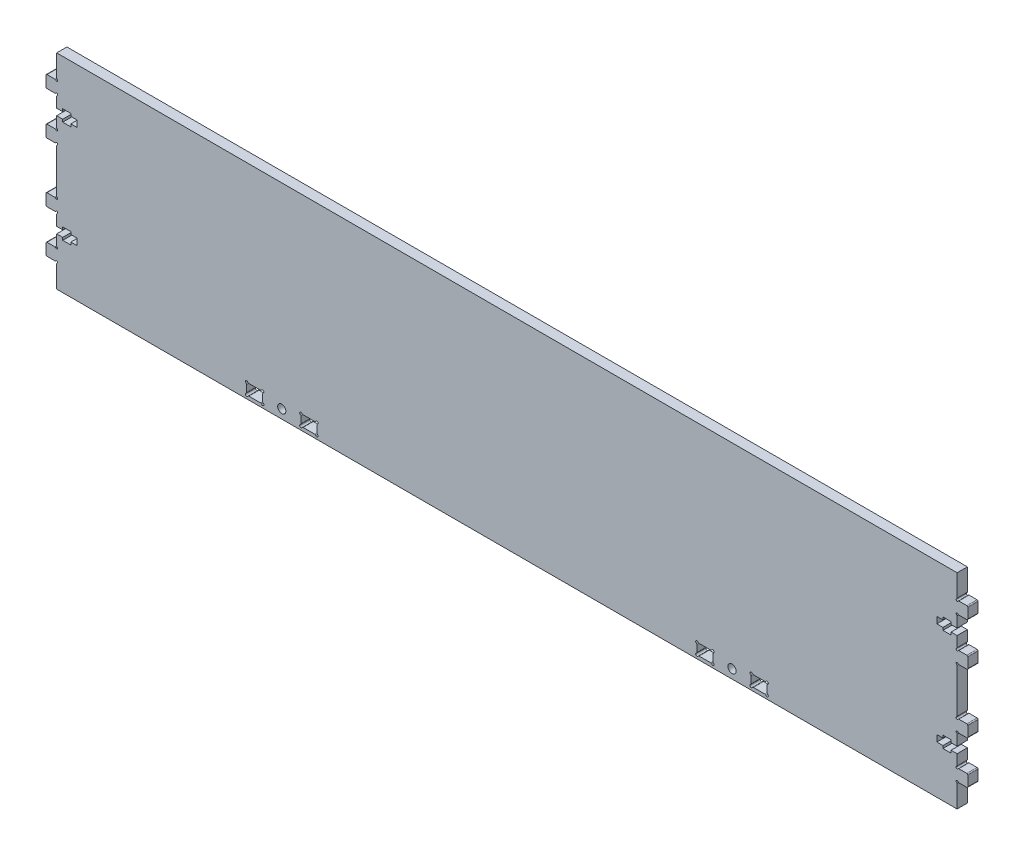
from build123d import *

# Parameters (mm, degrees)
CROQUIS1_R              = 1.6
SALIENTE_EXTRUIR1_DEPTH = 4


with BuildPart() as part:
    # Croquis1 → Saliente-Extruir1 (new body)
    with BuildSketch(Plane.XY):
        with BuildLine():
            Line((-175.998887973, 28.55134284), (-175.998887973, 11.44865157))
            ThreePointArc((-175.998887973, 11.44865157), (-175.94587303, 11.250797196), (-175.801033525, 11.105957783))
            ThreePointArc((-175.801033525, 11.105957783), (-175.719078995, 10.48345621), (-176.341580832, 10.56540874))
            ThreePointArc((-176.341580832, 10.56540874), (-176.486420159, 10.710247461), (-176.684273983, 10.763262086))
            Line((-176.684273983, 10.763262086), (-179.768889347, 10.763262086))
            ThreePointArc((-179.768889347, 10.763262086), (-180.048697583, 10.647361719), (-180.16459795, 10.367553483))
            Line((-180.16459795, 10.367553483), (-180.16459795, 6.410469053))
            ThreePointArc((-180.16459795, 6.410469053), (-180.048697583, 6.130660816), (-179.768889347, 6.01476045))
            Line((-179.768889347, 6.01476045), (-176.68427585, 6.01476045))
            ThreePointArc((-176.68427585, 6.01476045), (-176.48642016, 6.067776152), (-176.341580544, 6.212617529))
            ThreePointArc((-176.341580544, 6.212617529), (-175.719077577, 6.294574818), (-175.801032304, 5.672071513))
            ThreePointArc((-175.801032304, 5.672071513), (-175.945872678, 5.527232006), (-175.998887973, 5.329377021))
            Line((-175.998887973, 5.329377021), (-175.998887973, 1.266269087))
            Line((-175.998887973, 1.266269087), (-173.624658515, 1.266269087))
            Line((-173.624658515, 1.266269087), (-173.624658515, 2.275321276))
            Line((-173.624658515, 2.275321276), (-170.458967533, 2.275321276))
            Line((-170.458967533, 2.275321276), (-170.458967533, 1.266274677))
            Line((-170.458967533, 1.266274677), (-168.084715916, 1.266274677))
            Line((-168.084715916, 1.266274677), (-168.084715916, -1.266274677))
            Line((-168.084715916, -1.266274677), (-170.458967533, -1.266274677))
            Line((-170.458967533, -1.266274677), (-170.458967533, -2.275327657))
            Line((-170.458967533, -2.275327657), (-173.624658515, -2.275327657))
            Line((-173.624658515, -2.275327657), (-173.624658515, -1.266274677))
            Line((-173.624658515, -1.266274677), (-175.998887973, -1.266274677))
            Line((-175.998887973, -1.266274677), (-175.998887973, -5.329405863))
            ThreePointArc((-175.998887973, -5.329405863), (-175.945873032, -5.527260234), (-175.801033533, -5.672099645))
            ThreePointArc((-175.801033533, -5.672099645), (-175.719079017, -6.294601221), (-176.341580852, -6.212648677))
            ThreePointArc((-176.341580852, -6.212648677), (-176.48642018, -6.067809949), (-176.684274007, -6.014795323))
            Line((-176.684274007, -6.014795323), (-179.768889347, -6.014795323))
            ThreePointArc((-179.768889347, -6.014795323), (-180.048697583, -6.130695689), (-180.16459795, -6.410503926))
            Line((-180.16459795, -6.410503926), (-180.16459795, -10.367588371))
            ThreePointArc((-180.16459795, -10.367588371), (-180.048697583, -10.647396608), (-179.768889347, -10.763296974))
            Line((-179.768889347, -10.763296974), (-176.68427585, -10.763296974))
            ThreePointArc((-176.68427585, -10.763296974), (-176.486420241, -10.710281319), (-176.341580638, -10.565440059))
            ThreePointArc((-176.341580638, -10.565440059), (-175.719077737, -10.483482962), (-175.801032398, -11.105986184))
            ThreePointArc((-175.801032398, -11.105986184), (-175.945872705, -11.250825683), (-175.998887973, -11.448680621))
            Line((-175.998887973, -11.448680621), (-175.998887973, -20.000002795))
            Line((-175.998887973, -20.000002795), (176.001112027, -20.000002795))
            Line((176.001112027, -20.000002795), (176.001112027, -11.448677826))
            ThreePointArc((176.001112027, -11.448677826), (175.94809676, -11.250822888), (175.803256453, -11.105983388))
            ThreePointArc((175.803256453, -11.105983388), (175.721301792, -10.483480167), (176.343804693, -10.565437263))
            ThreePointArc((176.343804693, -10.565437263), (176.488644296, -10.710278524), (176.686499905, -10.763294179))
            Line((176.686499905, -10.763294179), (179.771113402, -10.763294179))
            ThreePointArc((179.771113402, -10.763294179), (180.050921638, -10.647393813), (180.166822004, -10.367585576))
            Line((180.166822004, -10.367585576), (180.166822004, -6.41050113))
            ThreePointArc((180.166822004, -6.41050113), (180.050921638, -6.130692894), (179.771113402, -6.014792528))
            Line((179.771113402, -6.014792528), (176.686498062, -6.014792528))
            ThreePointArc((176.686498062, -6.014792528), (176.488644235, -6.067807154), (176.343804907, -6.212645881))
            ThreePointArc((176.343804907, -6.212645881), (175.721303071, -6.294598426), (175.803257588, -5.67209685))
            ThreePointArc((175.803257588, -5.67209685), (175.948097087, -5.527257438), (176.001112027, -5.329403068))
            Line((176.001112027, -5.329403068), (176.001112027, -1.266271882))
            Line((176.001112027, -1.266271882), (173.62688257, -1.266271882))
            Line((173.62688257, -1.266271882), (173.62688257, -2.275324862))
            Line((173.62688257, -2.275324862), (170.461191588, -2.275324862))
            Line((170.461191588, -2.275324862), (170.461191588, -1.266271882))
            Line((170.461191588, -1.266271882), (168.086939971, -1.266271882))
            Line((168.086939971, -1.266271882), (168.086939971, 1.266271882))
            Line((168.086939971, 1.266271882), (170.461191588, 1.266271882))
            Line((170.461191588, 1.266271882), (170.461191588, 2.275324071))
            Line((170.461191588, 2.275324071), (173.62688257, 2.275324071))
            Line((173.62688257, 2.275324071), (173.62688257, 1.266271882))
            Line((173.62688257, 1.266271882), (176.001112027, 1.266271882))
            Line((176.001112027, 1.266271882), (176.001112027, 5.329379817))
            ThreePointArc((176.001112027, 5.329379817), (175.948096732, 5.527234802), (175.803256359, 5.672074308))
            ThreePointArc((175.803256359, 5.672074308), (175.721301631, 6.294577613), (176.343804599, 6.212620324))
            ThreePointArc((176.343804599, 6.212620324), (176.488644215, 6.067778947), (176.686499905, 6.014763245))
            Line((176.686499905, 6.014763245), (179.771113402, 6.014763245))
            ThreePointArc((179.771113402, 6.014763245), (180.050921638, 6.130663611), (180.166822004, 6.410471848))
            Line((180.166822004, 6.410471848), (180.166822004, 10.367556278))
            ThreePointArc((180.166822004, 10.367556278), (180.050921638, 10.647364515), (179.771113402, 10.763264881))
            Line((179.771113402, 10.763264881), (176.686498037, 10.763264881))
            ThreePointArc((176.686498037, 10.763264881), (176.488644214, 10.710250256), (176.343804886, 10.565411535))
            ThreePointArc((176.343804886, 10.565411535), (175.721303049, 10.483459005), (175.80325758, 11.105960579))
            ThreePointArc((175.80325758, 11.105960579), (175.948097085, 11.250799991), (176.001112027, 11.448654365))
            Line((176.001112027, 11.448654365), (176.001112027, 28.551340044))
            ThreePointArc((176.001112027, 28.551340044), (175.948097085, 28.749194419), (175.80325758, 28.894033831))
            ThreePointArc((175.80325758, 28.894033831), (175.721303049, 29.516535405), (176.343804886, 29.434582875))
            ThreePointArc((176.343804886, 29.434582875), (176.488644214, 29.289744153), (176.686498037, 29.236729529))
            Line((176.686498037, 29.236729529), (179.771113402, 29.236729529))
            ThreePointArc((179.771113402, 29.236729529), (180.050921638, 29.352629895), (180.166822004, 29.632438131))
            Line((180.166822004, 29.632438131), (180.166822004, 33.589522562))
            ThreePointArc((180.166822004, 33.589522562), (180.050921638, 33.869330798), (179.771113402, 33.985231164))
            Line((179.771113402, 33.985231164), (176.686499905, 33.985231164))
            ThreePointArc((176.686499905, 33.985231164), (176.488644215, 33.932215462), (176.343804599, 33.787374085))
            ThreePointArc((176.343804599, 33.787374085), (175.721301631, 33.705416797), (175.803256359, 34.327920101))
            ThreePointArc((175.803256359, 34.327920101), (175.948096732, 34.472759608), (176.001112027, 34.670614593))
            Line((176.001112027, 34.670614593), (176.001112027, 38.733722528))
            Line((176.001112027, 38.733722528), (173.62688257, 38.733722528))
            Line((173.62688257, 38.733722528), (173.62688257, 37.724670339))
            Line((173.62688257, 37.724670339), (170.461191588, 37.724670339))
            Line((170.461191588, 37.724670339), (170.461191588, 38.733722528))
            Line((170.461191588, 38.733722528), (168.086939971, 38.733722528))
            Line((168.086939971, 38.733722528), (168.086939971, 41.266266291))
            Line((168.086939971, 41.266266291), (170.461191588, 41.266266291))
            Line((170.461191588, 41.266266291), (170.461191588, 42.275319272))
            Line((170.461191588, 42.275319272), (173.62688257, 42.275319272))
            Line((173.62688257, 42.275319272), (173.62688257, 41.266266291))
            Line((173.62688257, 41.266266291), (176.001112027, 41.266266291))
            Line((176.001112027, 41.266266291), (176.001112027, 45.329397478))
            ThreePointArc((176.001112027, 45.329397478), (175.948097087, 45.527251848), (175.803257588, 45.67209126))
            ThreePointArc((175.803257588, 45.67209126), (175.721303071, 46.294592835), (176.343804907, 46.212640291))
            ThreePointArc((176.343804907, 46.212640291), (176.488644235, 46.067801564), (176.686498062, 46.014786937))
            Line((176.686498062, 46.014786937), (179.771113402, 46.014786937))
            ThreePointArc((179.771113402, 46.014786937), (180.050921638, 46.130687303), (180.166822004, 46.41049554))
            Line((180.166822004, 46.41049554), (180.166822004, 50.367579986))
            ThreePointArc((180.166822004, 50.367579986), (180.050921638, 50.647388222), (179.771113402, 50.763288589))
            Line((179.771113402, 50.763288589), (176.686499905, 50.763288589))
            ThreePointArc((176.686499905, 50.763288589), (176.488644296, 50.710272934), (176.343804693, 50.565431673))
            ThreePointArc((176.343804693, 50.565431673), (175.721301792, 50.483474576), (175.803256453, 51.105977798))
            ThreePointArc((175.803256453, 51.105977798), (175.94809676, 51.250817297), (176.001112027, 51.448672235))
            Line((176.001112027, 51.448672235), (176.001112027, 59.999997205))
            Line((176.001112027, 59.999997205), (-175.998887973, 59.999997205))
            Line((-175.998887973, 59.999997205), (-175.998887973, 51.44867503))
            ThreePointArc((-175.998887973, 51.44867503), (-175.945872705, 51.250820093), (-175.801032398, 51.105980593))
            ThreePointArc((-175.801032398, 51.105980593), (-175.719077737, 50.483477372), (-176.341580638, 50.565434468))
            ThreePointArc((-176.341580638, 50.565434468), (-176.486420241, 50.710275729), (-176.68427585, 50.763291384))
            Line((-176.68427585, 50.763291384), (-179.768889347, 50.763291384))
            ThreePointArc((-179.768889347, 50.763291384), (-180.048697583, 50.647391017), (-180.16459795, 50.367582781))
            Line((-180.16459795, 50.367582781), (-180.16459795, 46.410498335))
            ThreePointArc((-180.16459795, 46.410498335), (-180.048697583, 46.130690099), (-179.768889347, 46.014789732))
            Line((-179.768889347, 46.014789732), (-176.684274007, 46.014789732))
            ThreePointArc((-176.684274007, 46.014789732), (-176.48642018, 46.067804359), (-176.341580852, 46.212643086))
            ThreePointArc((-176.341580852, 46.212643086), (-175.719079017, 46.29459563), (-175.801033533, 45.672094055))
            ThreePointArc((-175.801033533, 45.672094055), (-175.945873032, 45.527254643), (-175.998887973, 45.329400273))
            Line((-175.998887973, 45.329400273), (-175.998887973, 41.266269087))
            Line((-175.998887973, 41.266269087), (-173.624658515, 41.266269087))
            Line((-173.624658515, 41.266269087), (-173.624658515, 42.275322067))
            Line((-173.624658515, 42.275322067), (-170.458967533, 42.275322067))
            Line((-170.458967533, 42.275322067), (-170.458967533, 41.266269087))
            Line((-170.458967533, 41.266269087), (-168.084715916, 41.266269087))
            Line((-168.084715916, 41.266269087), (-168.084715916, 38.733719732))
            Line((-168.084715916, 38.733719732), (-170.458967533, 38.733719732))
            Line((-170.458967533, 38.733719732), (-170.458967533, 37.724673134))
            Line((-170.458967533, 37.724673134), (-173.624658515, 37.724673134))
            Line((-173.624658515, 37.724673134), (-173.624658515, 38.733725323))
            Line((-173.624658515, 38.733725323), (-175.998887973, 38.733725323))
            Line((-175.998887973, 38.733725323), (-175.998887973, 34.670617388))
            ThreePointArc((-175.998887973, 34.670617388), (-175.945872678, 34.472762403), (-175.801032304, 34.327922896))
            ThreePointArc((-175.801032304, 34.327922896), (-175.719077577, 33.705419592), (-176.341580544, 33.78737688))
            ThreePointArc((-176.341580544, 33.78737688), (-176.48642016, 33.932218258), (-176.68427585, 33.98523396))
            Line((-176.68427585, 33.98523396), (-179.768889347, 33.98523396))
            ThreePointArc((-179.768889347, 33.98523396), (-180.048697583, 33.869333593), (-180.16459795, 33.589525357))
            Line((-180.16459795, 33.589525357), (-180.16459795, 29.632440927))
            ThreePointArc((-180.16459795, 29.632440927), (-180.048697583, 29.35263269), (-179.768889347, 29.236732324))
            Line((-179.768889347, 29.236732324), (-176.684273983, 29.236732324))
            ThreePointArc((-176.684273983, 29.236732324), (-176.486420159, 29.289746948), (-176.341580832, 29.43458567))
            ThreePointArc((-176.341580832, 29.43458567), (-175.719078995, 29.5165382), (-175.801033525, 28.894036626))
            ThreePointArc((-175.801033525, 28.894036626), (-175.94587303, 28.749197214), (-175.998887973, 28.55134284))
        make_face()
        with Locations((88.001112027, -16.500002795)):
            Circle(CROQUIS1_R, mode=Mode.SUBTRACT)
        with Locations((-87.998887973, -16.500002795)):
            Circle(CROQUIS1_R, mode=Mode.SUBTRACT)
        with BuildLine():
            Line((96.367130414, -14.350040138), (100.83508001, -14.350040138))
            ThreePointArc((100.83508001, -14.350040138), (101.085081969, -14.283051709), (101.268094973, -14.100036221))
            ThreePointArc((101.268094973, -14.100036221), (102.054661693, -13.996477278), (101.951110024, -14.783044955))
            ThreePointArc((101.951110024, -14.783044955), (101.768097383, -14.96605765), (101.70111011, -15.216057607))
            Line((101.70111011, -15.216057607), (101.70111011, -17.783927203))
            ThreePointArc((101.70111011, -17.783927203), (101.768097421, -18.033927226), (101.951110155, -18.216939931))
            ThreePointArc((101.951110155, -18.216939931), (102.054664397, -19.003505242), (101.268098613, -18.899954591))
            ThreePointArc((101.268098613, -18.899954591), (101.085086061, -18.716943264), (100.835087027, -18.649956524))
            Line((100.835087027, -18.649956524), (96.367137431, -18.649956524))
            ThreePointArc((96.367137431, -18.649956524), (96.117136765, -18.716944207), (95.93412396, -18.899957857))
            ThreePointArc((95.93412396, -18.899957857), (95.147558474, -19.003513955), (95.251108451, -18.216947664))
            ThreePointArc((95.251108451, -18.216947664), (95.434119704, -18.033935119), (95.501106414, -17.783936138))
            Line((95.501106414, -17.783936138), (95.501106414, -15.216068542))
            ThreePointArc((95.501106414, -15.216068542), (95.434119187, -14.966068665), (95.25110666, -14.783055982))
            ThreePointArc((95.25110666, -14.783055982), (95.147552946, -13.996490602), (95.93411866, -14.10004178))
            ThreePointArc((95.93411866, -14.10004178), (96.117131235, -14.283053314), (96.367130414, -14.350040138))
        make_face(mode=Mode.SUBTRACT)
        with BuildLine():
            Line((75.167130414, -14.350040138), (79.63508001, -14.350040138))
            ThreePointArc((79.63508001, -14.350040138), (79.885080422, -14.283052602), (80.068093188, -14.100039313))
            ThreePointArc((80.068093188, -14.100039313), (80.854658123, -13.996483462), (80.751109545, -14.783049354))
            ThreePointArc((80.751109545, -14.783049354), (80.568099104, -14.96606181), (80.501112724, -15.216060221))
            Line((80.501112724, -15.216060221), (80.501112724, -17.783929817))
            ThreePointArc((80.501112724, -17.783929817), (80.568100251, -18.033930214), (80.751113519, -18.216942978))
            ThreePointArc((80.751113519, -18.216942978), (80.85466864, -19.003508592), (80.068102477, -18.899957638))
            ThreePointArc((80.068102477, -18.899957638), (79.885089891, -18.716946003), (79.635090641, -18.649959138))
            Line((79.635090641, -18.649959138), (75.167141045, -18.649959138))
            ThreePointArc((75.167141045, -18.649959138), (74.917140379, -18.716946821), (74.734127574, -18.89996047))
            ThreePointArc((74.734127574, -18.89996047), (73.947562088, -19.003516569), (74.051112065, -18.216950277))
            ThreePointArc((74.051112065, -18.216950277), (74.234123318, -18.033937733), (74.301110027, -17.783938752))
            Line((74.301110027, -17.783938752), (74.301110027, -15.216071156))
            ThreePointArc((74.301110027, -15.216071156), (74.234122345, -14.96607049), (74.051108695, -14.783057685))
            ThreePointArc((74.051108695, -14.783057685), (73.947552596, -13.996492199), (74.734118888, -14.100042176))
            ThreePointArc((74.734118888, -14.100042176), (74.917131432, -14.283053428), (75.167130414, -14.350040138))
        make_face(mode=Mode.SUBTRACT)
        with BuildLine():
            Line((-101.698889973, -17.783938752), (-101.698889973, -15.216071156))
            ThreePointArc((-101.698889973, -15.216071156), (-101.765877655, -14.96607049), (-101.948891305, -14.783057685))
            ThreePointArc((-101.948891305, -14.783057685), (-102.052447404, -13.996492199), (-101.265881112, -14.100042176))
            ThreePointArc((-101.265881112, -14.100042176), (-101.082868568, -14.283053428), (-100.832869586, -14.350040138))
            Line((-100.832869586, -14.350040138), (-96.36491999, -14.350040138))
            ThreePointArc((-96.36491999, -14.350040138), (-96.114919578, -14.283052602), (-95.931906812, -14.100039313))
            ThreePointArc((-95.931906812, -14.100039313), (-95.145341877, -13.996483462), (-95.248890455, -14.783049354))
            ThreePointArc((-95.248890455, -14.783049354), (-95.431900896, -14.96606181), (-95.498887276, -15.216060221))
            Line((-95.498887276, -15.216060221), (-95.498887276, -17.783929817))
            ThreePointArc((-95.498887276, -17.783929817), (-95.431899749, -18.033930214), (-95.248886481, -18.216942978))
            ThreePointArc((-95.248886481, -18.216942978), (-95.14533136, -19.003508592), (-95.931897523, -18.899957638))
            ThreePointArc((-95.931897523, -18.899957638), (-96.114910109, -18.716946003), (-96.364909359, -18.649959138))
            Line((-96.364909359, -18.649959138), (-100.832858955, -18.649959138))
            ThreePointArc((-100.832858955, -18.649959138), (-101.082859621, -18.716946821), (-101.265872426, -18.89996047))
            ThreePointArc((-101.265872426, -18.89996047), (-102.052437912, -19.003516569), (-101.948887935, -18.216950277))
            ThreePointArc((-101.948887935, -18.216950277), (-101.765876682, -18.033937733), (-101.698889973, -17.783938752))
        make_face(mode=Mode.SUBTRACT)
        with BuildLine():
            Line((-74.29888989, -15.216057607), (-74.29888989, -17.783927203))
            ThreePointArc((-74.29888989, -17.783927203), (-74.231902579, -18.033927226), (-74.048889845, -18.216939931))
            ThreePointArc((-74.048889845, -18.216939931), (-73.945335603, -19.003505242), (-74.731901387, -18.899954591))
            ThreePointArc((-74.731901387, -18.899954591), (-74.914913939, -18.716943264), (-75.164912973, -18.649956524))
            Line((-75.164912973, -18.649956524), (-79.632862569, -18.649956524))
            ThreePointArc((-79.632862569, -18.649956524), (-79.882863235, -18.716944207), (-80.06587604, -18.899957857))
            ThreePointArc((-80.06587604, -18.899957857), (-80.852441526, -19.003513955), (-80.748891549, -18.216947664))
            ThreePointArc((-80.748891549, -18.216947664), (-80.565880296, -18.033935119), (-80.498893586, -17.783936138))
            Line((-80.498893586, -17.783936138), (-80.498893586, -15.216068542))
            ThreePointArc((-80.498893586, -15.216068542), (-80.565880813, -14.966068665), (-80.74889334, -14.783055982))
            ThreePointArc((-80.74889334, -14.783055982), (-80.852447054, -13.996490602), (-80.06588134, -14.10004178))
            ThreePointArc((-80.06588134, -14.10004178), (-79.882868765, -14.283053314), (-79.632869586, -14.350040138))
            Line((-79.632869586, -14.350040138), (-75.16491999, -14.350040138))
            ThreePointArc((-75.16491999, -14.350040138), (-74.914918031, -14.283051709), (-74.731905027, -14.100036221))
            ThreePointArc((-74.731905027, -14.100036221), (-73.945338307, -13.996477278), (-74.048889976, -14.783044955))
            ThreePointArc((-74.048889976, -14.783044955), (-74.231902617, -14.96605765), (-74.29888989, -15.216057607))
        make_face(mode=Mode.SUBTRACT)
    extrude(amount=SALIENTE_EXTRUIR1_DEPTH)


solid = part.part
